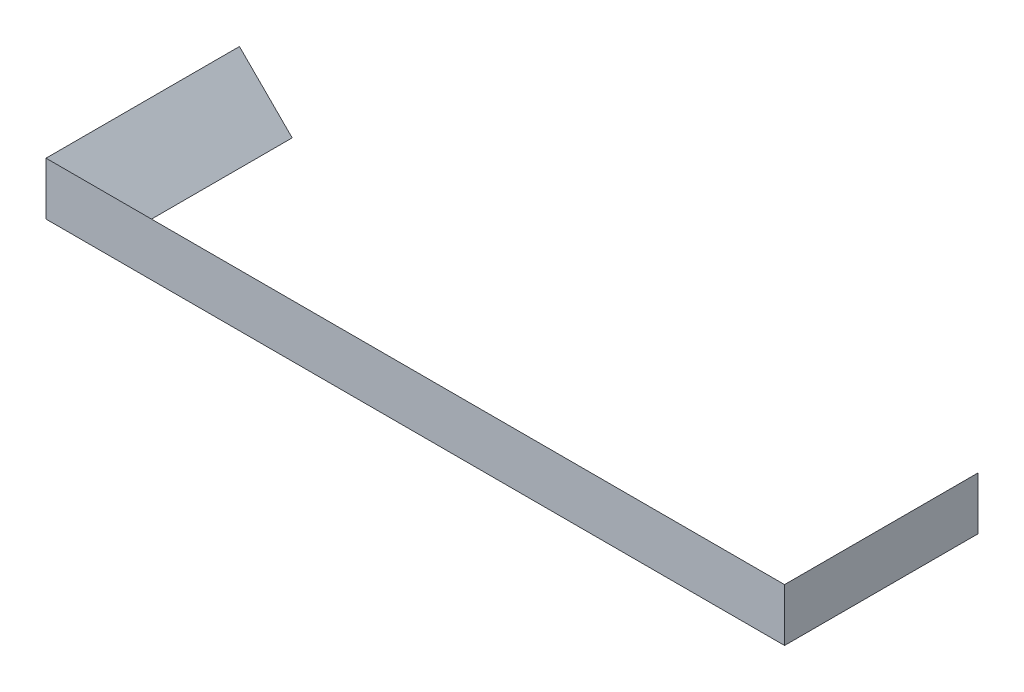
from build123d import *


with BuildPart() as part:
    # По траектории1: sweep along a path in Эскиз1
    with BuildLine(Plane(origin=(0, 0, 0), x_dir=(1, 0, 0), z_dir=(0, 1, 0))) as sweep_1_path:
        Line((0, 0), (0, -22))
        Line((0, -22), (84, -22))
        Line((84, -22), (84, 0))
    # Эскиз2 → По траектории1 (sweep)
    with BuildSketch(Plane.XY):
        Polygon((6, 0), (0, 0), (0, 6), align=None)
    sweep(path=sweep_1_path.line, transition=Transition.RIGHT)


solid = part.part
